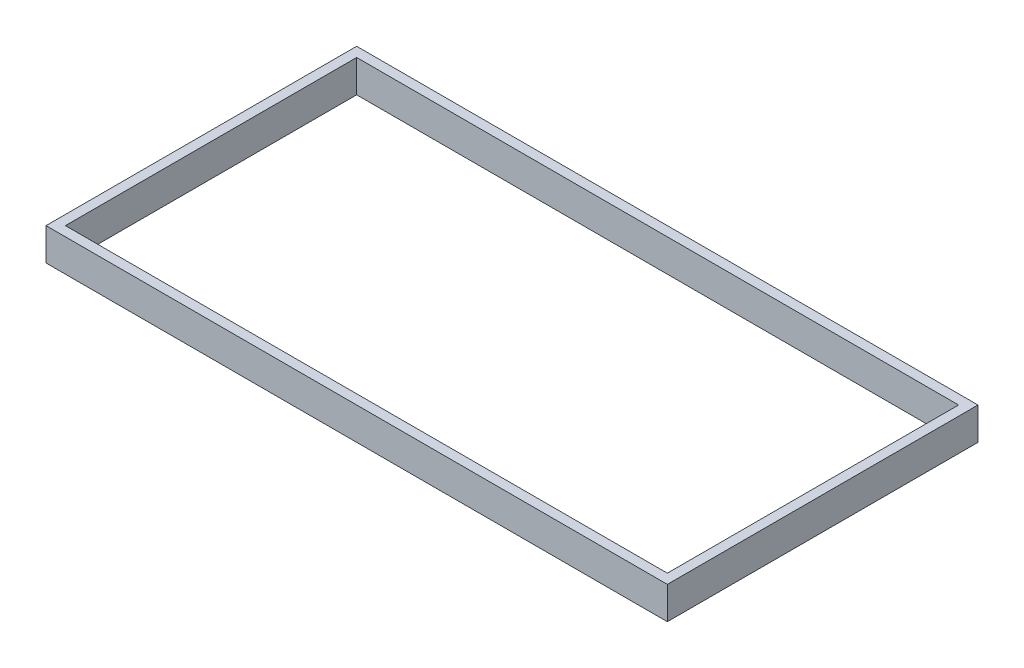
from build123d import *

# Parameters (mm, degrees)
SKETCH1_W           = 1219.2
SKETCH1_H           = 609.6
SKETCH1_W_2         = 1181.1
SKETCH1_H_2         = 571.5
BOSS_EXTRUDE1_DEPTH = 63.5


with BuildPart() as part:
    # Sketch1 → Boss-Extrude1 (new body)
    with BuildSketch(Plane(origin=(0, 0, 0), x_dir=(1, 0, 0), z_dir=(0, 1, 0))):
        Rectangle(SKETCH1_W, SKETCH1_H)
        Rectangle(SKETCH1_W_2, SKETCH1_H_2, mode=Mode.SUBTRACT)
    extrude(amount=BOSS_EXTRUDE1_DEPTH)


solid = part.part
